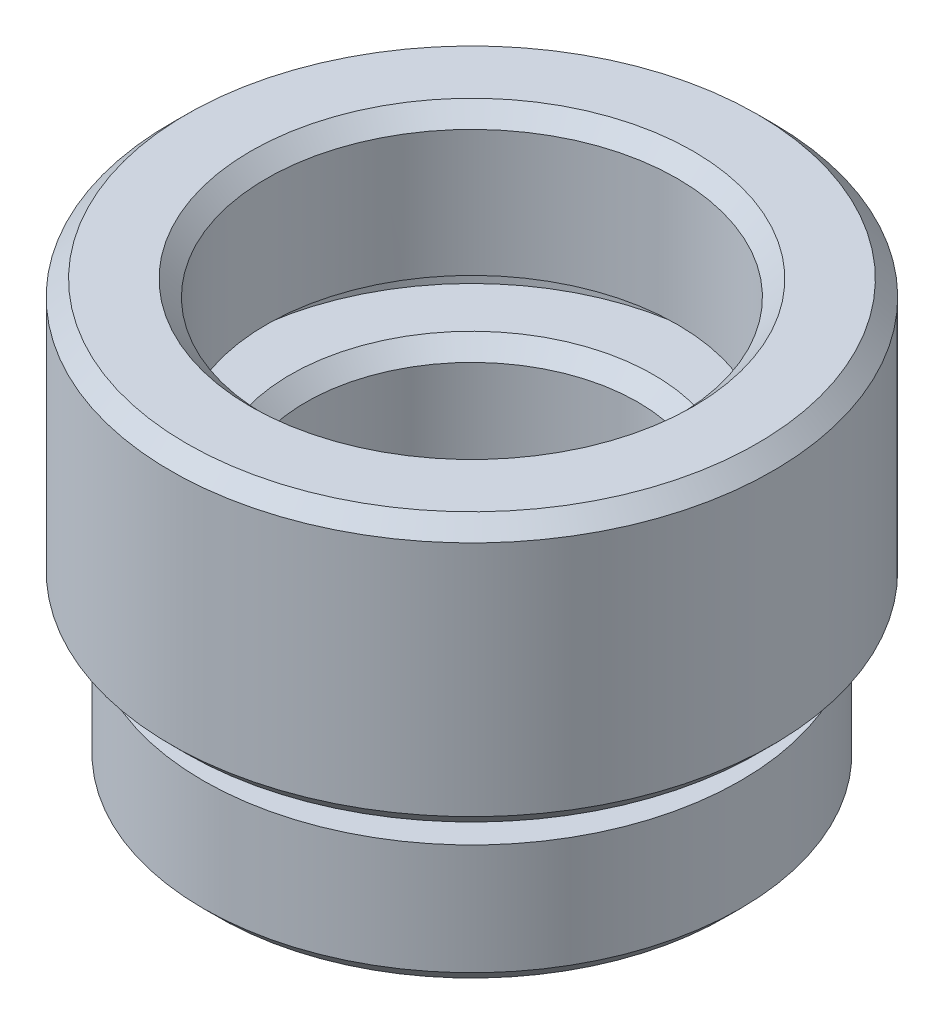
from build123d import *

# Parameters (mm, degrees)
CHAMFER_1_SIZE = 0.5


with BuildPart() as part:
    # 草图1 → 旋转1 (revolve)
    with BuildSketch(Plane.XY, mode=Mode.PRIVATE) as revolve_1_sk:
        Polygon((4.5, 0), (4.5, 2), (5, 2), (5, 3.5), (6.35, 3.5), (6.35, 4.5), (5.25, 4.5), (5.25, 8), (7.6, 8), (7.6, 9), (6.5, 9), (6.5, 13.5), (9.025, 13.5), (9.525, 13), (9.525, 5.5), (9.025, 5), (7, 5), (7, 4), (8.5, 4), (8.5, 0.5), (8, 0), align=None)
    revolve(revolve_1_sk.sketch.rotate(Axis((0, 0, 0), (0, 1, 0)), 90), axis=Axis((0, 0, 0), (0, 1, 0)))  # turned: the seam where the file's is

    # 倒角1
    chamfer_1_edges = [part.edges().sort_by_distance(p)[0] for p in [
        (0, 8, 5.25),
        (0, 13.5, 6.5),
    ]]
    chamfer(chamfer_1_edges, length=CHAMFER_1_SIZE)


solid = part.part
